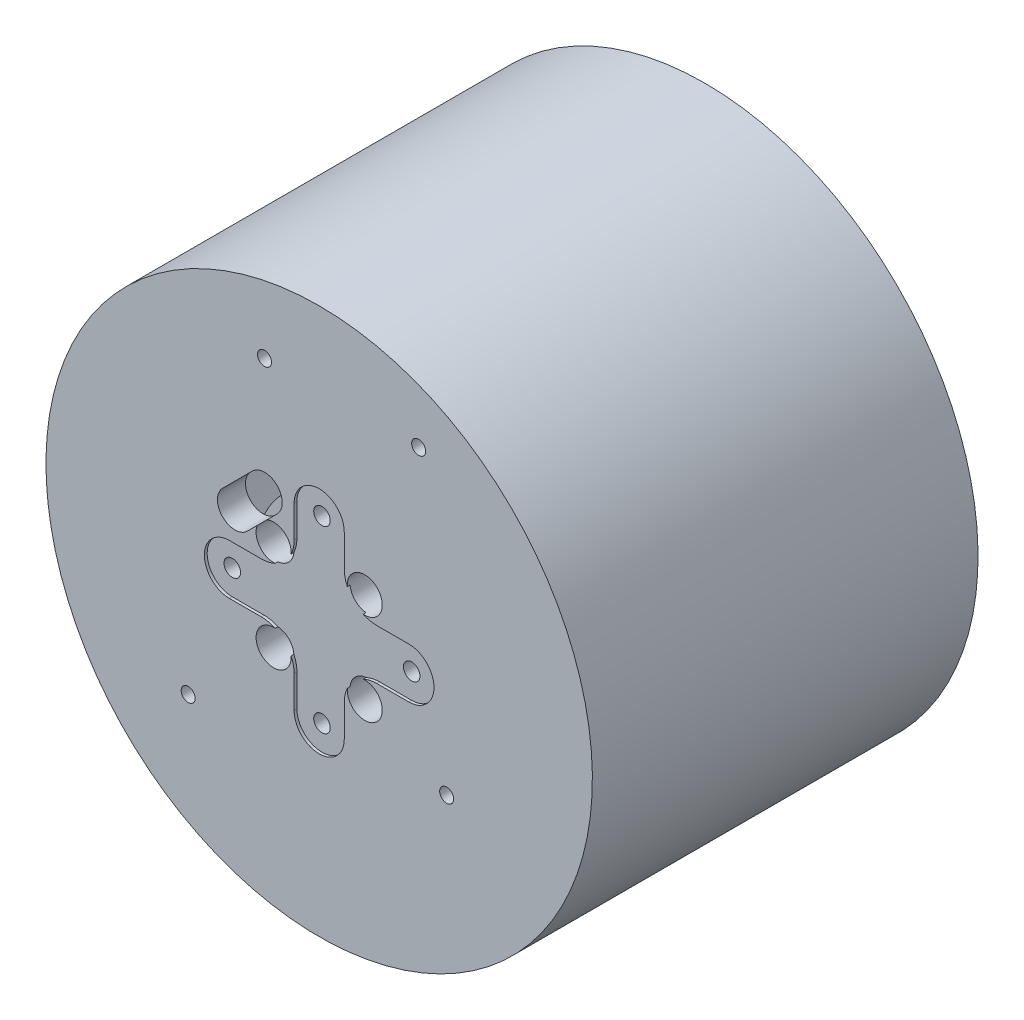
from build123d import *

# Parameters (mm, degrees)
X_WING_DEPTH       = 12.7
SKETCH4_3_R        = 1.5
SKETCH4_3_R_2      = 3.175
HOLES_DEPTH        = 9.525
CHIP_DEPTH         = 6.35
EXTRUDE_9V_DEPTH   = 15.24
SKETCH6_3_R        = 1.27
AIR_HOLES_DEPTH    = 9.525
SKETCH7_W          = 7.542953633
SKETCH7_H          = 7.880697826
SKETCH7_H_2        = 6.417139658
SKETCH7_W_2        = 5.741651273
SKETCH7_H_3        = 8.218442018
AIR_SLOTS_DEPTH    = 1.27
CUT_EXTRUDE1_START = 4.572
SKETCH4_5_R        = 1.5
CUT_EXTRUDE1_DEPTH = 0.508


with BuildPart() as part:
    # Sketch2 → Body (revolve)
    with BuildSketch(Plane(origin=(0, 0, 0), x_dir=(0, 0, -1), z_dir=(1, 0, 0))):
        Polygon((4.4704, 13.9065), (0, 12.5857), (0, 0), (-5.08, 0), (-5.08, 49.53), (64.831152593, 49.53), (64.831152593, 39.37), (59.751152593, 39.37), (59.751152593, 44.45), (0, 44.45), (0, 16.4465), (4.4704, 16.4465), align=None)
    revolve(axis=Axis((0, 0, 0), (0, 0, 1)))

    # Sketch4 → X-Wing (cut)
    with BuildSketch(Plane.XY):
        with BuildLine():
            Line((-4.1656, -12.04250002), (-4.1656, -10.483480973))
            ThreePointArc((-4.1656, -10.483480973), (-6.016064494, -6.016064494), (-10.483480973, -4.1656))
            Line((-10.483480973, -4.1656), (-16.265, -4.1656))
            ThreePointArc((-16.265, -4.1656), (-20.4306, 0), (-16.265, 4.1656))
            Line((-16.265, 4.1656), (-12.04250002, 4.1656))
            Line((-12.04250002, 4.1656), (-10.483480973, 4.1656))
            ThreePointArc((-10.483480973, 4.1656), (-6.016064494, 6.016064494), (-4.1656, 10.483480973))
            Line((-4.1656, 10.483480973), (-4.1656, 12.04250002))
            Line((-4.1656, 12.04250002), (-4.1656, 16.265))
            ThreePointArc((-4.1656, 16.265), (0, 20.4306), (4.1656, 16.265))
            Line((4.1656, 16.265), (4.1656, 12.04250002))
            Line((4.1656, 12.04250002), (4.1656, 10.483480973))
            ThreePointArc((4.1656, 10.483480973), (6.016064494, 6.016064494), (10.483480973, 4.1656))
            Line((10.483480973, 4.1656), (12.04250002, 4.1656))
            Line((12.04250002, 4.1656), (16.265, 4.1656))
            ThreePointArc((16.265, 4.1656), (20.4306, 0), (16.265, -4.1656))
            Line((16.265, -4.1656), (12.04250002, -4.1656))
            Line((12.04250002, -4.1656), (10.483480973, -4.1656))
            ThreePointArc((10.483480973, -4.1656), (6.016064494, -6.016064494), (4.1656, -10.483480973))
            Line((4.1656, -10.483480973), (4.1656, -12.04250002))
            Line((4.1656, -12.04250002), (4.1656, -16.265))
            ThreePointArc((4.1656, -16.265), (0, -20.4306), (-4.1656, -16.265))
            Line((-4.1656, -16.265), (-4.1656, -12.04250002))
        make_face()
    extrude(amount=-X_WING_DEPTH, mode=Mode.SUBTRACT)

    # Sketch4_3 → Holes (cut)
    with BuildSketch(Plane.XY):
        with Locations(Location((0, -16.265, 0), (0, 0, 180))):
            Circle(SKETCH4_3_R)
        with Locations(Location((-16.265, 0, 0), (0, 0, 180))):
            Circle(SKETCH4_3_R)
        with Locations(Location((16.265, 0, 0), (0, 0, 180))):
            Circle(SKETCH4_3_R)
        with Locations(Location((0, 16.265, 0), (0, 0, 180))):
            Circle(SKETCH4_3_R)
        with BuildLine():
            ThreePointArc((-7.633217703, 13.021371376), (-7.633217703, 17.511499436), (-12.123345763, 17.511499436))
            Line((-12.123345763, 17.511499436), (-17.511499436, 12.123345763))
            ThreePointArc((-17.511499436, 12.123345763), (-17.511499436, 7.633217703), (-13.021371376, 7.633217703))
            Line((-13.021371376, 7.633217703), (-7.633217703, 13.021371376))
        make_face()
        with Locations((-8.261128525, 8.261128525)):
            Circle(SKETCH4_3_R_2)
        with Locations(Location((8.261128525, 8.261128525, 0), (0, 0, 125.826899667))):
            Circle(SKETCH4_3_R_2)
        with Locations(Location((8.261128525, -8.261128525, 0), (0, 0, 234.173100333))):
            Circle(SKETCH4_3_R_2)
        with Locations(Location((-8.261128525, -8.261128525, 0), (0, 0, 144.173100333))):
            Circle(SKETCH4_3_R_2)
    extrude(amount=HOLES_DEPTH, mode=Mode.SUBTRACT)

    # Sketch6 → Chip (add)
    with BuildSketch(Plane.XY.offset(5.08)):
        Polygon((11.350015507, 22.225), (-11.715690517, 22.225), (-12.954, 22.225), (-12.954, 16.6808452), (-12.7, 16.9348452), (-12.7, 20.32), (12.7, 20.32), (12.7, -20.32), (-12.7, -20.32), (-12.7, 7.954589078), (-12.954, 7.700589078), (-12.954, -22.225), (12.954, -22.225), (12.954, 22.225), align=None)
    extrude(amount=CHIP_DEPTH)

    # Sketch6_4 → Extrude 9V (add)
    with BuildSketch(Plane.XY.offset(5.08)):
        Polygon((-14.859, 14.7758452), (-12.954, 16.6808452), (-12.954, 22.225), (-11.715690517, 22.225), (-11.715690517, 23.479848526), (-14.859, 23.479848526), align=None)
        with BuildLine():
            ThreePointArc((-13.021371376, 7.633217703), (-13.865328691, 7.029154679), (-14.859, 6.729532555))
            Line((-14.859, 6.729532555), (-14.859, 0.522650935))
            ThreePointArc((-14.859, 0.522650935), (-14.765, 0), (-14.859, -0.522650935))
            Line((-14.859, -0.522650935), (-14.859, -24.638))
            Line((-14.859, -24.638), (14.859, -24.638))
            Line((14.859, -24.638), (14.859, -0.522650935))
            ThreePointArc((14.859, -0.522650935), (14.765, 0), (14.859, 0.522650935))
            Line((14.859, 0.522650935), (14.859, 29.972))
            Line((14.859, 29.972), (-14.859, 29.972))
            Line((-14.859, 29.972), (-14.859, 28.067))
            Line((-14.859, 28.067), (12.954, 28.067))
            Line((12.954, 28.067), (12.954, 23.734213344))
            Line((12.954, 23.734213344), (11.350015507, 23.734213344))
            Line((11.350015507, 23.734213344), (11.350015507, 22.225))
            Line((11.350015507, 22.225), (12.954, 22.225))
            Line((12.954, 22.225), (12.954, -22.733))
            Line((12.954, -22.733), (-12.954, -22.733))
            Line((-12.954, -22.733), (-12.954, 7.700589078))
            Line((-12.954, 7.700589078), (-13.021371376, 7.633217703))
        make_face()
    extrude(amount=EXTRUDE_9V_DEPTH)

    # Sketch6_3 → Air holes (cut)
    with BuildSketch(Plane.XY.offset(5.08)):
        with Locations((-23.749, -23.368)):
            Circle(SKETCH6_3_R)
        with Locations((23.114, -15.748)):
            Circle(SKETCH6_3_R)
        with Locations((-9.906, 36.322)):
            Circle(SKETCH6_3_R)
        with Locations((18.034, 36.322)):
            Circle(SKETCH6_3_R)
    extrude(amount=-AIR_HOLES_DEPTH, mode=Mode.SUBTRACT)

    # Sketch7 → Air Slots (cut)
    with BuildSketch(Plane.XY.offset(5.08)):
        with Locations((15.537525525, 8.731732869)):
            Rectangle(SKETCH7_W, SKETCH7_H)
        with Locations((15.537525525, -8.324348854)):
            Rectangle(SKETCH7_W, SKETCH7_H_2)
        with Locations((-14.859451804, -9.225000034)):
            Rectangle(SKETCH7_W_2, SKETCH7_H_3)
    extrude(amount=AIR_SLOTS_DEPTH, mode=Mode.SUBTRACT)

    # SurfaceCut1
    split(bisect_by=Plane.XY.offset(5.08), keep=Keep.BOTTOM)

    # Sketch4_5 → Cut-Extrude1 (cut)
    with BuildSketch(Plane.XY.offset(CUT_EXTRUDE1_START)):
        with BuildLine():
            ThreePointArc((5.098211557, -7.98439534), (6.016064494, -6.016064494), (7.98439534, -5.098211557))
            ThreePointArc((7.98439534, -5.098211557), (9.203861468, -4.686142824), (10.483480973, -4.5466))
            Line((10.483480973, -4.5466), (16.265, -4.5466))
            ThreePointArc((16.265, -4.5466), (20.8116, 0), (16.265, 4.5466))
            Line((16.265, 4.5466), (10.483480973, 4.5466))
            ThreePointArc((10.483480973, 4.5466), (9.203861468, 4.686142824), (7.98439534, 5.098211557))
            ThreePointArc((7.98439534, 5.098211557), (6.016064494, 6.016064494), (5.098211557, 7.98439534))
            ThreePointArc((5.098211557, 7.98439534), (4.686142824, 9.203861468), (4.5466, 10.483480973))
            Line((4.5466, 10.483480973), (4.5466, 16.265))
            ThreePointArc((4.5466, 16.265), (0, 20.8116), (-4.5466, 16.265))
            Line((-4.5466, 16.265), (-4.5466, 10.483480973))
            ThreePointArc((-4.5466, 10.483480973), (-4.686142824, 9.203861468), (-5.098211557, 7.98439534))
            ThreePointArc((-5.098211557, 7.98439534), (-6.016064494, 6.016064494), (-7.98439534, 5.098211557))
            ThreePointArc((-7.98439534, 5.098211557), (-9.203861468, 4.686142824), (-10.483480973, 4.5466))
            Line((-10.483480973, 4.5466), (-16.265, 4.5466))
            ThreePointArc((-16.265, 4.5466), (-20.8116, 0), (-16.265, -4.5466))
            Line((-16.265, -4.5466), (-10.483480973, -4.5466))
            ThreePointArc((-10.483480973, -4.5466), (-9.203861468, -4.686142824), (-7.98439534, -5.098211557))
            ThreePointArc((-7.98439534, -5.098211557), (-6.016064494, -6.016064494), (-5.098211557, -7.98439534))
            ThreePointArc((-5.098211557, -7.98439534), (-4.686142824, -9.203861468), (-4.5466, -10.483480973))
            Line((-4.5466, -10.483480973), (-4.5466, -16.265))
            ThreePointArc((-4.5466, -16.265), (0, -20.8116), (4.5466, -16.265))
            Line((4.5466, -16.265), (4.5466, -10.483480973))
            ThreePointArc((4.5466, -10.483480973), (4.686142824, -9.203861468), (5.098211557, -7.98439534))
        make_face()
        with Locations(Location((0, -16.265, 0), (0, 0, 180))):
            Circle(SKETCH4_5_R, mode=Mode.SUBTRACT)
        with Locations(Location((16.265, 0, 0), (0, 0, 180))):
            Circle(SKETCH4_5_R, mode=Mode.SUBTRACT)
        with Locations(Location((-16.265, 0, 0), (0, 0, 180))):
            Circle(SKETCH4_5_R, mode=Mode.SUBTRACT)
        with Locations(Location((0, 16.265, 0), (0, 0, 180))):
            Circle(SKETCH4_5_R, mode=Mode.SUBTRACT)
    extrude(amount=CUT_EXTRUDE1_DEPTH, mode=Mode.SUBTRACT)


solid = part.part
